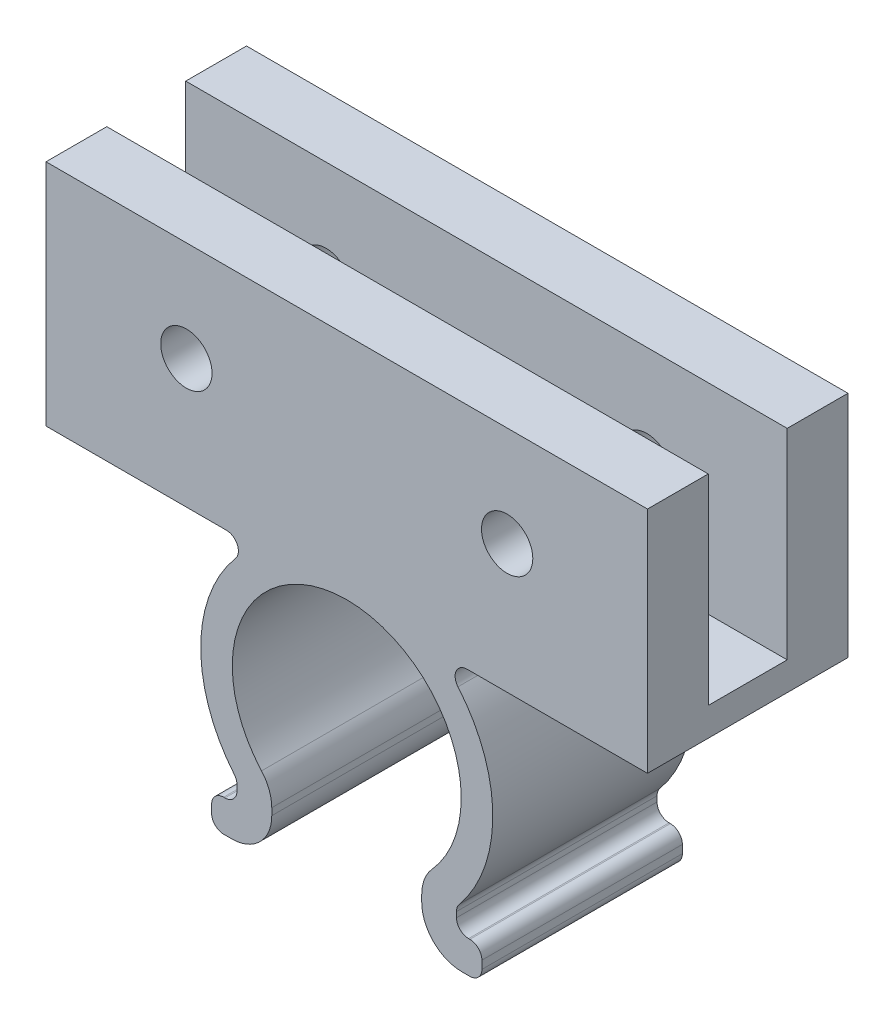
from build123d import *

# Parameters (mm, degrees)
BOSS_EXTRUDE1_DEPTH     = 12.7
SKETCH5_W               = 5
SKETCH5_H               = 12.7
CUT_EXTRUDE2_DEPTH      = 1
CUT_EXTRUDE2_DEPTH_BACK = 39.1
SKETCH6_R               = 1.625
CUT_EXTRUDE3_DEPTH      = 13.7
FILLET1_R               = 2.54
FILLET2_R               = 0.762


with BuildPart() as part:
    # Sketch1 → Boss-Extrude1 (new body)
    with BuildSketch(Plane.XY):
        with BuildLine():
            Line((-4.75, -6.123225575), (-4.75, -10.16))
            Line((-4.75, -10.16), (-8.56, -10.16))
            Line((-8.56, -10.16), (-8.56, -8.128))
            Line((-8.56, -8.128), (-6.953663109, -8.128))
            Line((-6.953663109, -8.128), (-6.953663109, -6.745923719))
            ThreePointArc((-6.953663109, -6.745923719), (-9.212293425, 0.188355946), (-5.744562647, 6.604))
            Line((-5.744562647, 6.604), (-19.05, 6.604))
            Line((-19.05, 6.604), (-19.05, 21.104))
            Line((-19.05, 21.104), (19.05, 21.104))
            Line((19.05, 21.104), (19.05, 6.604))
            Line((19.05, 6.604), (5.744562647, 6.604))
            ThreePointArc((5.744562647, 6.604), (9.212293425, 0.188355946), (6.953663109, -6.745923719))
            Line((6.953663109, -6.745923719), (6.953663109, -8.128))
            Line((6.953663109, -8.128), (8.56, -8.128))
            Line((8.56, -8.128), (8.56, -10.16))
            Line((8.56, -10.16), (4.75, -10.16))
            Line((4.75, -10.16), (4.75, -6.123225575))
            ThreePointArc((4.75, -6.123225575), (0, 6.604), (-4.75, -6.123225575))
        make_face()
    extrude(amount=BOSS_EXTRUDE1_DEPTH)

    # Sketch5 → Cut-Extrude2 (cut, two sides)
    with BuildSketch(Plane.ZY.offset(19.05)) as cut_extrude2_sk:
        with Locations((6.35, 14.754)):
            Rectangle(SKETCH5_W, SKETCH5_H)
    extrude(amount=CUT_EXTRUDE2_DEPTH, mode=Mode.SUBTRACT)
    extrude(cut_extrude2_sk.sketch, amount=-CUT_EXTRUDE2_DEPTH_BACK, mode=Mode.SUBTRACT)

    # Sketch6 → Cut-Extrude3 (cut, through all)
    with BuildSketch(Plane.XY.offset(12.7)):
        with Locations((-10.16, 14.754)):
            Circle(SKETCH6_R)
        with Locations((10.16, 14.754)):
            Circle(SKETCH6_R)
    extrude(amount=-CUT_EXTRUDE3_DEPTH, mode=Mode.SUBTRACT)

    # Fillet1
    fillet1_edges = [part.edges().sort_by_distance(p)[0] for p in [
        (4.75, -10.16, 6.35),
        (4.75, -6.123225575, 6.35),
        (-4.75, -6.123225575, 6.35),
        (-4.75, -10.16, 6.35),
    ]]
    fillet(fillet1_edges, radius=FILLET1_R)

    # Fillet2
    fillet2_edges = [part.edges().sort_by_distance(p)[0] for p in [
        (-8.56, -8.128, 6.35),
        (-6.953663109, -8.128, 6.35),
        (-6.953663109, -6.745923719, 6.35),
        (-5.744562647, 6.604, 6.35),
        (5.744562647, 6.604, 6.35),
        (6.953663109, -6.745923719, 6.35),
        (6.953663109, -8.128, 6.35),
        (8.56, -8.128, 6.35),
        (8.56, -10.16, 6.35),
        (-8.56, -10.16, 6.35),
    ]]
    fillet(fillet2_edges, radius=FILLET2_R)


solid = part.part
